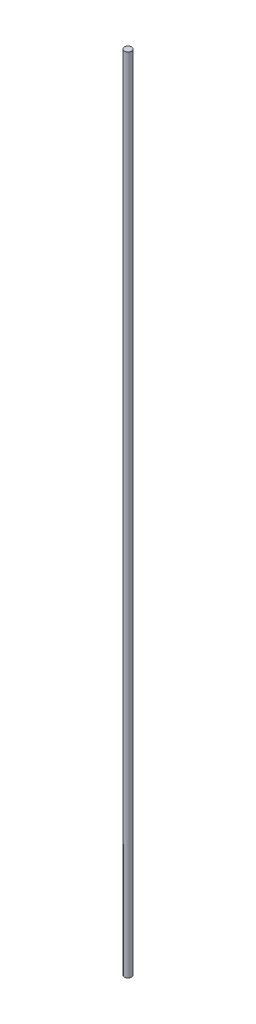
from build123d import *

# Parameters (mm, degrees)
SKETCH1_R           = 1
BOSS_EXTRUDE1_DEPTH = 220


with BuildPart() as part:
    # Sketch1 → Boss-Extrude1 (new body)
    with BuildSketch(Plane(origin=(0, 0, 0), x_dir=(1, 0, 0), z_dir=(0, 1, 0))):
        Circle(SKETCH1_R)
    extrude(amount=BOSS_EXTRUDE1_DEPTH)


solid = part.part
